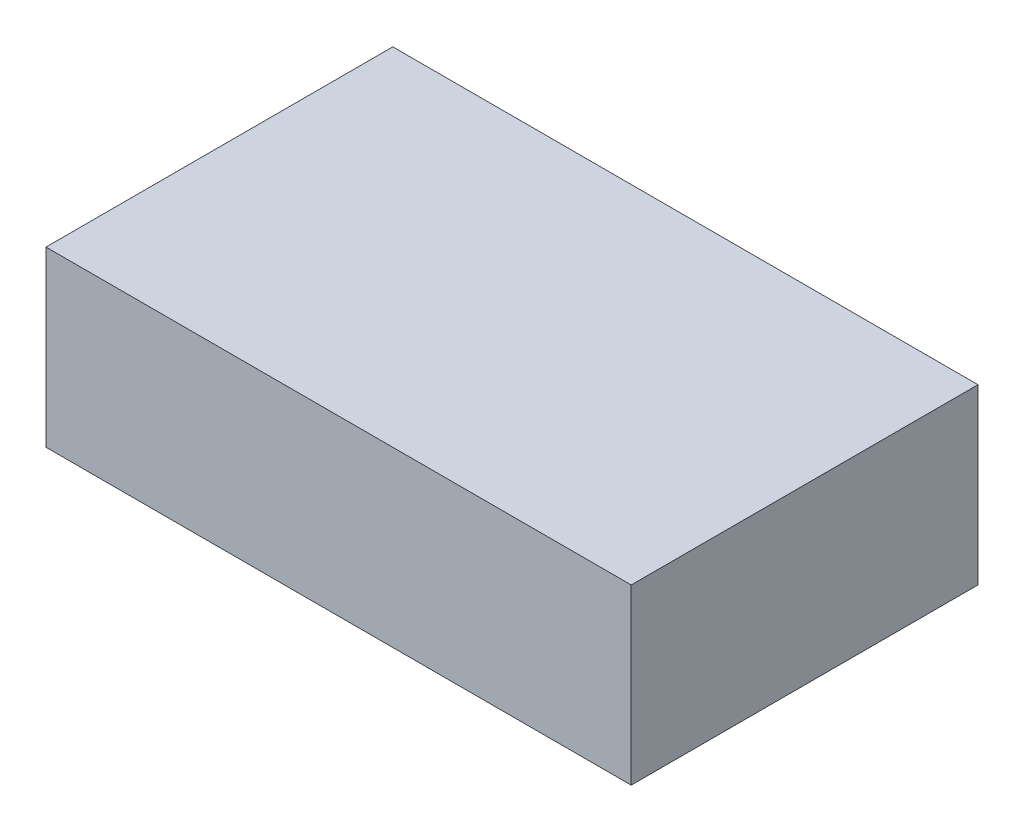
from build123d import *

# Parameters (mm, degrees)
SKETCH1_W           = 171.45
SKETCH1_H           = 101.6
BOSS_EXTRUDE1_DEPTH = 25.4


with BuildPart() as part:
    # Sketch1 → Boss-Extrude1 (new body, symmetric)
    with BuildSketch(Plane(origin=(0, 0, 0), x_dir=(1, 0, 0), z_dir=(0, 1, 0))):
        Rectangle(SKETCH1_W, SKETCH1_H)
    extrude(amount=BOSS_EXTRUDE1_DEPTH, both=True)


solid = part.part
